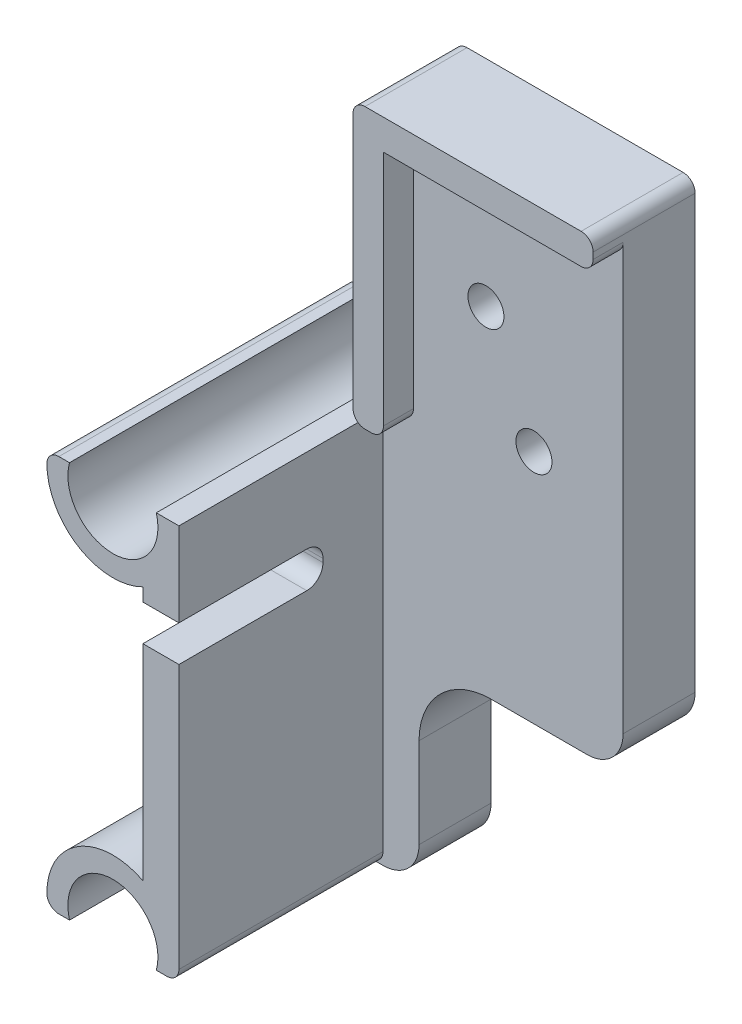
from build123d import *

# Parameters (mm, degrees)
SKETCH1_R           = 3.75
BOSS_EXTRUDE1_DEPTH = 25
FILLET1_R           = 2
SKETCH3_W           = 20
SKETCH3_H           = 19
CUT_EXTRUDE2_DEPTH  = 6
FILLET2_R           = 3
SKETCH7_W           = 32.058329052
SKETCH7_H           = 42.536839165
CUT_EXTRUDE5_DEPTH  = 25
SKETCH10_W          = 12.254265393
SKETCH10_H          = 5.748315633
SKETCH10_W_2        = 13.681746689
SKETCH10_H_2        = 5.503604554
CUT_EXTRUDE6_DEPTH  = 25
SKETCH11_W          = 6
SKETCH11_H          = 56.5
BOSS_EXTRUDE2_DEPTH = 20
CUT_EXTRUDE9_DEPTH  = 3
CUT_EXTRUDE11_DEPTH = 10
BOSS_EXTRUDE3_DEPTH = 2.5
FILLET5_R           = 3
FILLET6_R           = 1
SKETCH17_R          = 1.5
CUT_EXTRUDE12_DEPTH = 10


with BuildPart() as part:
    # Sketch1 → Boss-Extrude1 (new body)
    with BuildSketch(Plane.XY):
        with BuildLine():
            Line((-21, 16.5), (-21, -16.5))
            Line((-21, -16.5), (-16.5, -21))
            Line((-16.5, -21), (16.5, -21))
            Line((16.5, -21), (21, -16.5))
            Line((21, -16.5), (21, 16.5))
            Line((21, 16.5), (16.5, 21))
            Line((16.5, 21), (11.125, 21))
            Line((11.125, 21), (11.125, 18))
            Line((11.125, 18), (10.601020514, 18))
            ThreePointArc((10.601020514, 18), (11.610912703, 11.610912703), (18, 10.601020514))
            Line((18, 10.601020514), (18, -10.601020514))
            ThreePointArc((18, -10.601020514), (11.610912703, -11.610912703), (10.601020514, -18))
            Line((10.601020514, -18), (-10.601020514, -18))
            ThreePointArc((-10.601020514, -18), (-11.610912703, -11.610912703), (-18, -10.601020514))
            Line((-18, -10.601020514), (-18, 10.601020514))
            ThreePointArc((-18, 10.601020514), (-11.610912703, 11.610912703), (-10.601020514, 18))
            Line((-10.601020514, 18), (-11.125, 18))
            Line((-11.125, 18), (-11.125, 21))
            Line((-11.125, 21), (-16.5, 21))
            Line((-16.5, 21), (-21, 16.5))
        make_face()
        with Locations((-15.5, 15.5)):
            Circle(SKETCH1_R, mode=Mode.SUBTRACT)
        with Locations((15.5, 15.5)):
            Circle(SKETCH1_R, mode=Mode.SUBTRACT)
        with Locations((15.5, -15.5)):
            Circle(SKETCH1_R, mode=Mode.SUBTRACT)
        with Locations((-15.5, -15.5)):
            Circle(SKETCH1_R, mode=Mode.SUBTRACT)
    extrude(amount=BOSS_EXTRUDE1_DEPTH)

    # Fillet1
    fillet1_edges = [part.edges().sort_by_distance(p)[0] for p in [
        (-21, -16.5, 12.5),
        (-21, 16.5, 12.5),
        (-16.5, 21, 12.5),
        (-16.5, -21, 12.5),
    ]]
    fillet(fillet1_edges, radius=FILLET1_R)

    # Sketch3 → Cut-Extrude2 (cut)
    with BuildSketch(Plane(origin=(0, -21, 0), x_dir=(-1, 0, 0), z_dir=(0, -1, 0))):
        with Locations((0, -12.5)):
            Rectangle(SKETCH3_W, SKETCH3_H)
    extrude(amount=-CUT_EXTRUDE2_DEPTH, mode=Mode.SUBTRACT)

    # Fillet2
    fillet2_edges = [part.edges().sort_by_distance(p)[0] for p in [
        (10, -19.5, 22),
        (-10, -19.5, 3),
        (-10, -19.5, 22),
        (10, -19.5, 3),
    ]]
    fillet(fillet2_edges, radius=FILLET2_R)

    # Sketch7 → Cut-Extrude5 (cut)
    with BuildSketch(Plane.XY.offset(25)):
        with Locations((-6.029164526, 0.268419582)):
            Rectangle(SKETCH7_W, SKETCH7_H)
    extrude(amount=-CUT_EXTRUDE5_DEPTH, mode=Mode.SUBTRACT)

    # Sketch10 → Cut-Extrude6 (cut)
    with BuildSketch(Plane.XY.offset(25)):
        with Locations((14.872867304, 19.374157817)):
            Rectangle(SKETCH10_W, SKETCH10_H)
        with Locations((14.159126655, -19.251802277)):
            Rectangle(SKETCH10_W_2, SKETCH10_H_2)
    extrude(amount=-CUT_EXTRUDE6_DEPTH, mode=Mode.SUBTRACT)

    # Sketch11 → Boss-Extrude2 (add)
    with BuildSketch(Plane(origin=(21, 0, 0), x_dir=(0, 0, -1), z_dir=(1, 0, 0))):
        with Locations((-5, 11.75)):
            Rectangle(SKETCH11_W, SKETCH11_H)
    extrude(amount=BOSS_EXTRUDE2_DEPTH)

    # Sketch13 → Cut-Extrude9 (cut)
    with BuildSketch(Plane(origin=(21, 0, 0), x_dir=(0, 0, -1), z_dir=(1, 0, 0))):
        with BuildLine():
            Line((-25, 9.5), (-14.35, 9.5))
            ThreePointArc((-14.35, 9.5), (-13.395405845, 9.104594155), (-13, 8.15))
            Line((-13, 8.15), (-13, 7.85))
            ThreePointArc((-13, 7.85), (-13.395405845, 6.895405845), (-14.35, 6.5))
            Line((-14.35, 6.5), (-25, 6.5))
            Line((-25, 6.5), (-25, 9.5))
        make_face()
    extrude(amount=-CUT_EXTRUDE9_DEPTH, mode=Mode.SUBTRACT)

    # Sketch15 → Cut-Extrude11 (cut)
    with BuildSketch(Plane.XY.offset(8)):
        with BuildLine():
            Line((24, -16.5), (24, -6))
            ThreePointArc((24, -6), (25.757359313, -1.757359313), (30, 0))
            Line((30, 0), (41, 0))
            Line((41, 0), (41, -16.5))
            Line((41, -16.5), (24, -16.5))
        make_face()
    extrude(amount=-CUT_EXTRUDE11_DEPTH, mode=Mode.SUBTRACT)

    # Sketch16 → Boss-Extrude3 (add)
    with BuildSketch(Plane.XY.offset(8)):
        Polygon((21, 40), (41, 40), (41, 37.461788715), (23.538211285, 37.478793923), (23.538211285, 16.726527219), (21, 16.726527219), (21, 37.478793923), align=None)
    extrude(amount=BOSS_EXTRUDE3_DEPTH)

    # Fillet5
    fillet5_edges = [part.edges().sort_by_distance(p)[0] for p in [
        (41, 0, 5),
        (24, -16.5, 5),
    ]]
    fillet(fillet5_edges, radius=FILLET5_R)

    # Fillet6
    fillet6_edges = [part.edges().sort_by_distance(p)[0] for p in [
        (10.091673087, 16.5, 12.5),
        (10.091673087, -16.5, 12.5),
        (21, 16.5, 1),
        (21, -16.5, 1),
        (21, 40, 6.25),
        (41, 40, 6.25),
        (21, 16.726527219, 9.25),
        (23.538211285, 16.726527219, 9.25),
        (41, 37.461788715, 9.25),
        (21, -16.5, 16.5),
    ]]
    fillet(fillet6_edges, radius=FILLET6_R)

    # Sketch17 → Cut-Extrude12 (cut)
    with BuildSketch(Plane.XY.offset(8)):
        with Locations((29.574223118, 28.11574528)):
            Circle(SKETCH17_R)
        with Locations((33.574223119, 19.642947284)):
            Circle(SKETCH17_R)
    extrude(amount=-CUT_EXTRUDE12_DEPTH, mode=Mode.SUBTRACT)


solid = part.part
